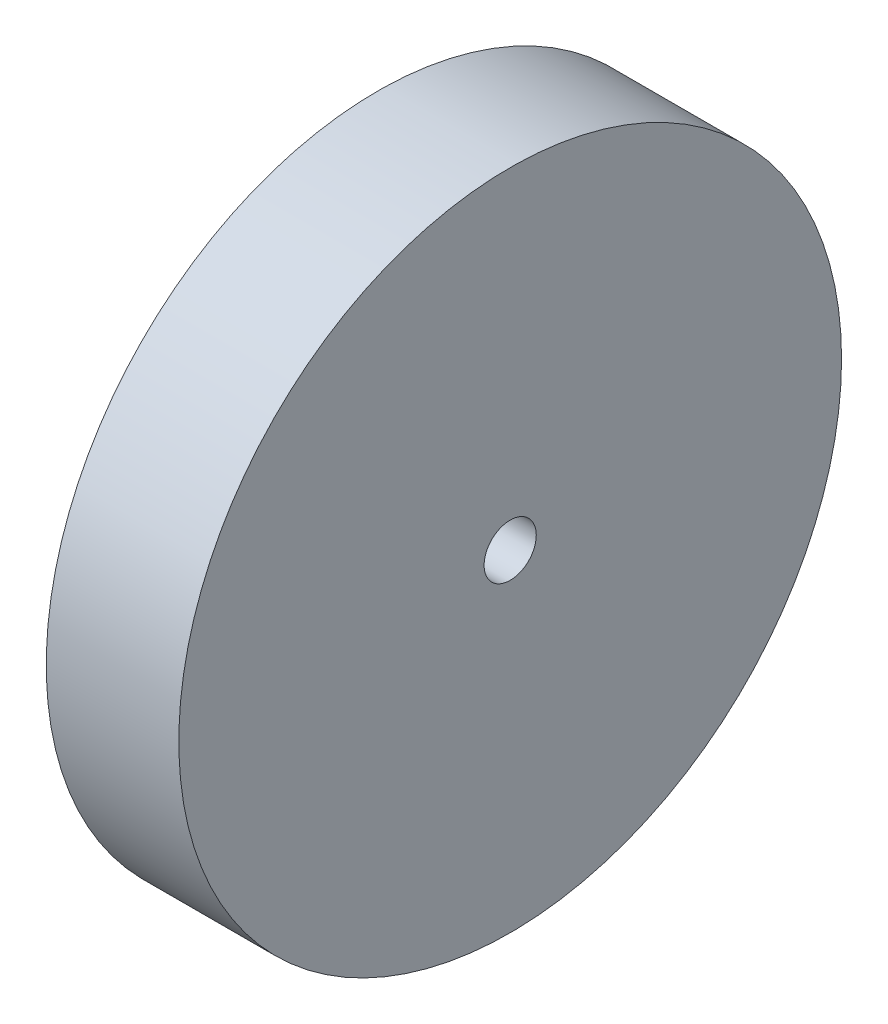
from build123d import *

# Parameters (mm, degrees)
SKETCH1_R           = 31.75
SKETCH1_R_2         = 2.5
BOSS_EXTRUDE1_DEPTH = 12.7


with BuildPart() as part:
    # Sketch1 → Boss-Extrude1 (new body)
    with BuildSketch(Plane(origin=(0, 0, 0), x_dir=(0, 0, -1), z_dir=(1, 0, 0))):
        Circle(SKETCH1_R)
        Circle(SKETCH1_R_2, mode=Mode.SUBTRACT)
    extrude(amount=BOSS_EXTRUDE1_DEPTH)


solid = part.part
